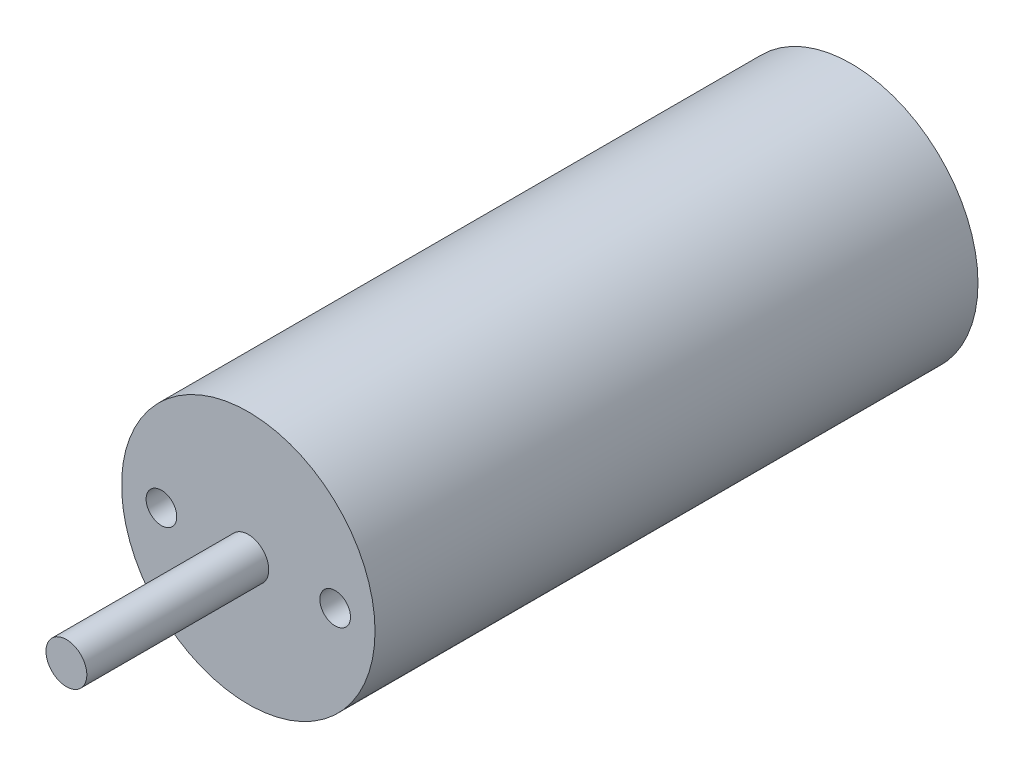
from build123d import *

# Parameters (mm, degrees)
SKETCH1_R           = 12.4
BOSS_EXTRUDE1_DEPTH = 59
SKETCH2_R           = 2
BOSS_EXTRUDE2_DEPTH = 17.8
SKETCH3_R           = 1.5
CUT_EXTRUDE1_DEPTH  = 4.3942


with BuildPart() as part:
    # Sketch1 → Boss-Extrude1 (new body)
    with BuildSketch(Plane.XY):
        with Locations((12.4, 0)):
            Circle(SKETCH1_R)
    extrude(amount=BOSS_EXTRUDE1_DEPTH)

    # Sketch2 → Boss-Extrude2 (add)
    with BuildSketch(Plane.XY.offset(59)):
        with Locations((12.4, 0)):
            Circle(SKETCH2_R)
    extrude(amount=BOSS_EXTRUDE2_DEPTH)

    # Sketch3 → Cut-Extrude1 (cut)
    with BuildSketch(Plane.XY.offset(59)):
        with Locations((20.9, 0)):
            Circle(SKETCH3_R)
        with Locations((3.9, 0)):
            Circle(SKETCH3_R)
    extrude(amount=-CUT_EXTRUDE1_DEPTH, mode=Mode.SUBTRACT)


solid = part.part
